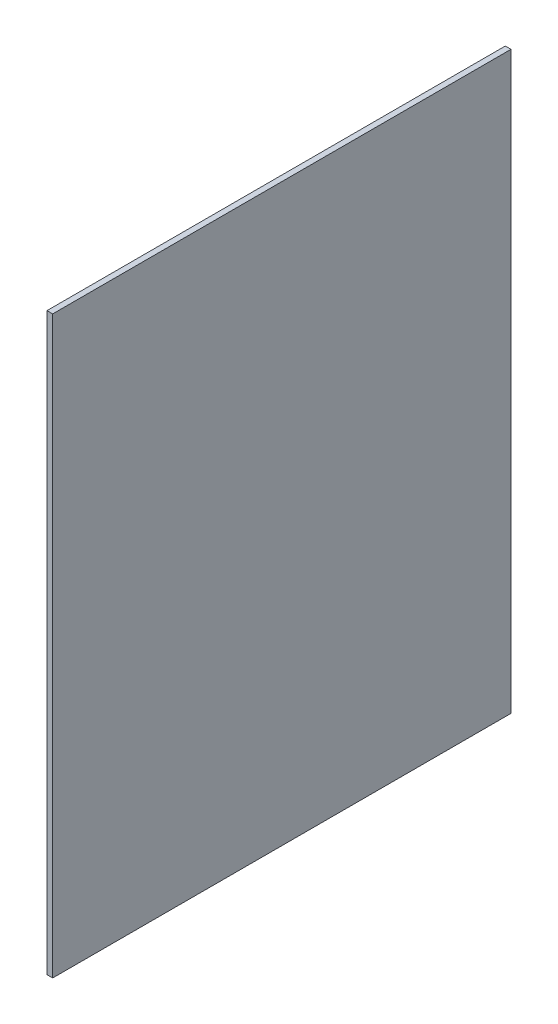
from build123d import *

# Parameters (mm, degrees)
SKETCH1_W           = 1.39446
SKETCH1_H           = 140.88108
BOSS_EXTRUDE1_DEPTH = 112.268


with BuildPart() as part:
    # Sketch1 → Boss-Extrude1 (new body)
    with BuildSketch(Plane.XY):
        with Locations((151.57831, -70.44054)):
            Rectangle(SKETCH1_W, SKETCH1_H)
    extrude(amount=BOSS_EXTRUDE1_DEPTH)


solid = part.part
